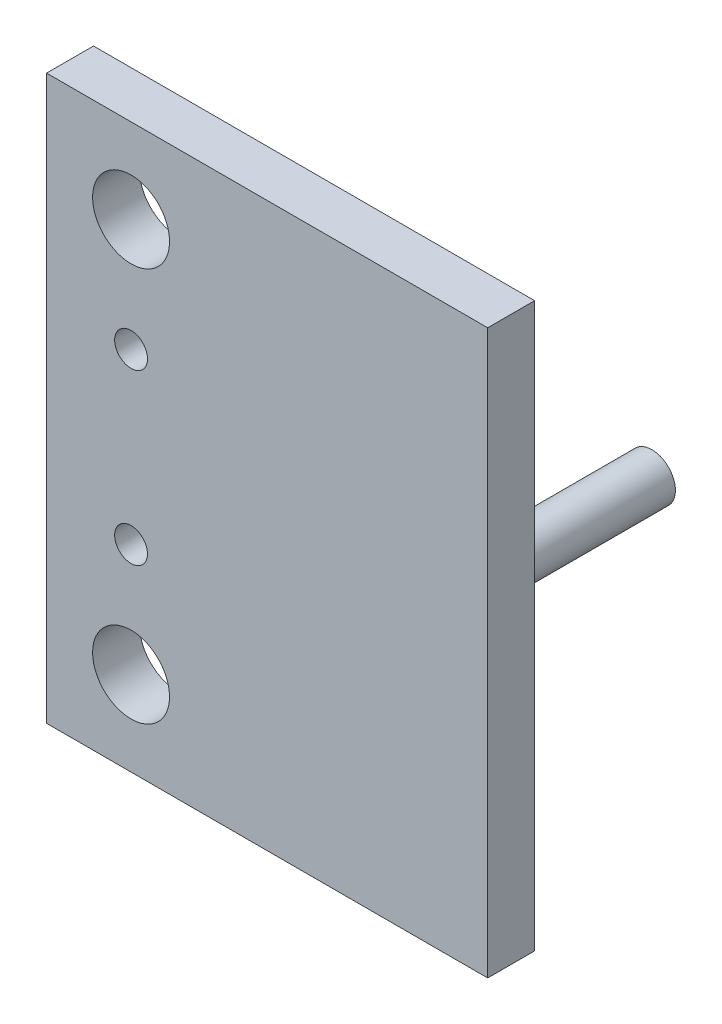
from build123d import *

# Parameters (mm, degrees)
SKETCH1_W           = 5
SKETCH1_H           = 60
BOSS_EXTRUDE1_DEPTH = 5
SKETCH2_W           = 5
SKETCH2_H           = 60
BOSS_EXTRUDE2_DEPTH = 20
SKETCH3_R           = 2.5
BOSS_EXTRUDE3_DEPTH = 20
SKETCH4_W           = 5
SKETCH4_H           = 60
BOSS_EXTRUDE4_DEPTH = 22
SKETCH5_R           = 4.1
SKETCH5_R_2         = 1.75
CUT_EXTRUDE1_DEPTH  = 6


with BuildPart() as part:
    # Sketch1 → Boss-Extrude1 (new body)
    with BuildSketch(Plane(origin=(0, 0, 0), x_dir=(0, 0, -1), z_dir=(1, 0, 0))):
        with Locations((10.587248322, 7.600671141)):
            Rectangle(SKETCH1_W, SKETCH1_H)
    extrude(amount=BOSS_EXTRUDE1_DEPTH)

    # Sketch2 → Boss-Extrude2 (add)
    with BuildSketch(Plane(origin=(5, 0, 0), x_dir=(0, 0, -1), z_dir=(1, 0, 0))):
        with Locations((10.587248322, 7.600671141)):
            Rectangle(SKETCH2_W, SKETCH2_H)
    extrude(amount=BOSS_EXTRUDE2_DEPTH)

    # Sketch3 → Boss-Extrude3 (add)
    with BuildSketch(Plane(origin=(0, 0, -13.087248322), x_dir=(-1, 0, 0), z_dir=(0, 0, -1))):
        with Locations((-17.5, 7.600671141)):
            Circle(SKETCH3_R)
    extrude(amount=BOSS_EXTRUDE3_DEPTH)

    # Sketch4 → Boss-Extrude4 (add)
    with BuildSketch(Plane.ZY):
        with Locations((-10.587248322, 7.600671141)):
            Rectangle(SKETCH4_W, SKETCH4_H)
    extrude(amount=BOSS_EXTRUDE4_DEPTH)

    # Sketch5 → Cut-Extrude1 (cut, through all)
    with BuildSketch(Plane(origin=(0, 0, -13.087248322), x_dir=(-1, 0, 0), z_dir=(0, 0, -1))):
        with Locations((13, 28.600671141)):
            Circle(SKETCH5_R)
        with Locations((13, -13.399328859)):
            Circle(SKETCH5_R)
        with Locations((13, -1.399328859)):
            Circle(SKETCH5_R_2)
        with Locations((13, 16.600671141)):
            Circle(SKETCH5_R_2)
    extrude(amount=-CUT_EXTRUDE1_DEPTH, mode=Mode.SUBTRACT)


solid = part.part
